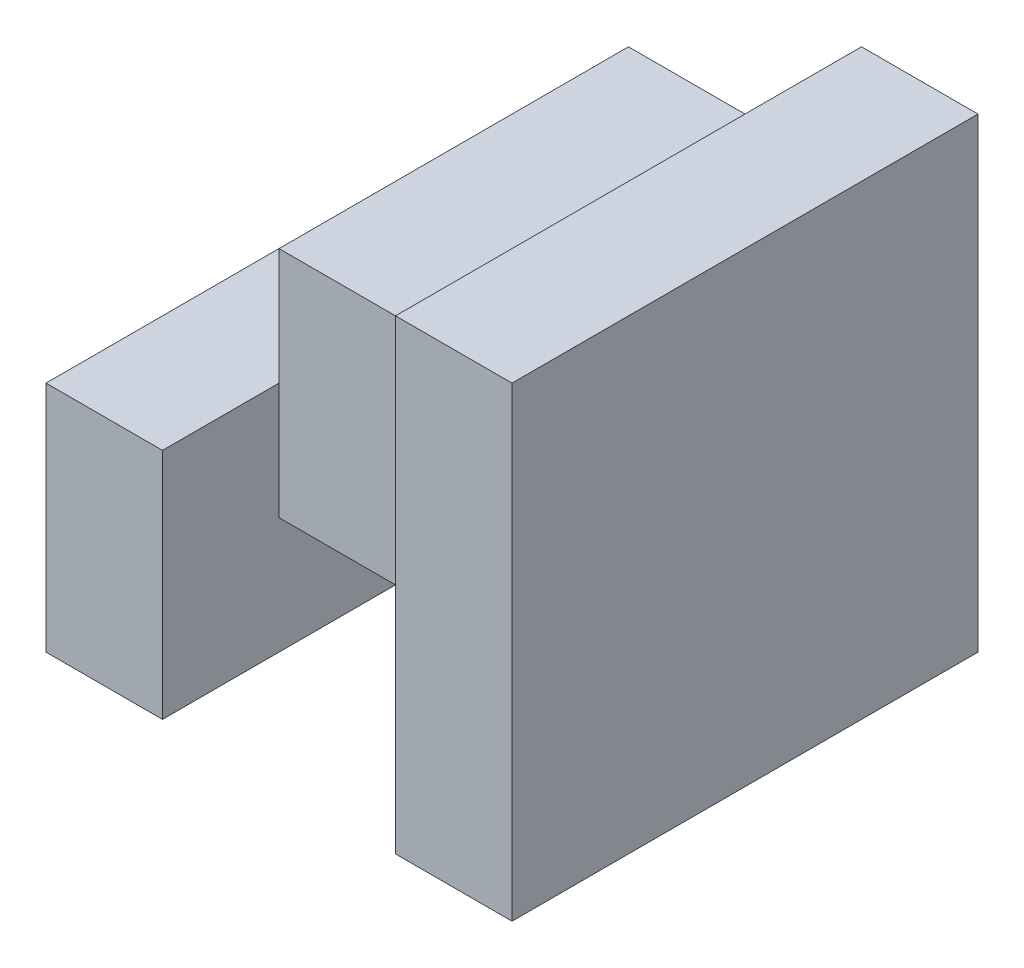
from build123d import *

# Parameters (mm, degrees)
BOSS_EXTRUDE1_DEPTH = 4
SKETCH2_W           = 2
SKETCH2_H           = 3
CUT_EXTRUDE1_DEPTH  = 1


with BuildPart() as part:
    # Sketch1 → Boss-Extrude1 (new body)
    with BuildSketch(Plane.XY):
        Polygon((0, 0), (0, 2), (1, 2), (1, 3), (3, 3), (3, 4), (4, 4), (4, 0), (3, 0), (3, 1), (1, 1), (1, 0), align=None)
    extrude(amount=BOSS_EXTRUDE1_DEPTH)

    # Sketch2 → Cut-Extrude1 (cut)
    with BuildSketch(Plane.XY.offset(4)):
        with Locations((2, 1.5)):
            Rectangle(SKETCH2_W, SKETCH2_H)
    extrude(amount=-CUT_EXTRUDE1_DEPTH, mode=Mode.SUBTRACT)


solid = part.part
